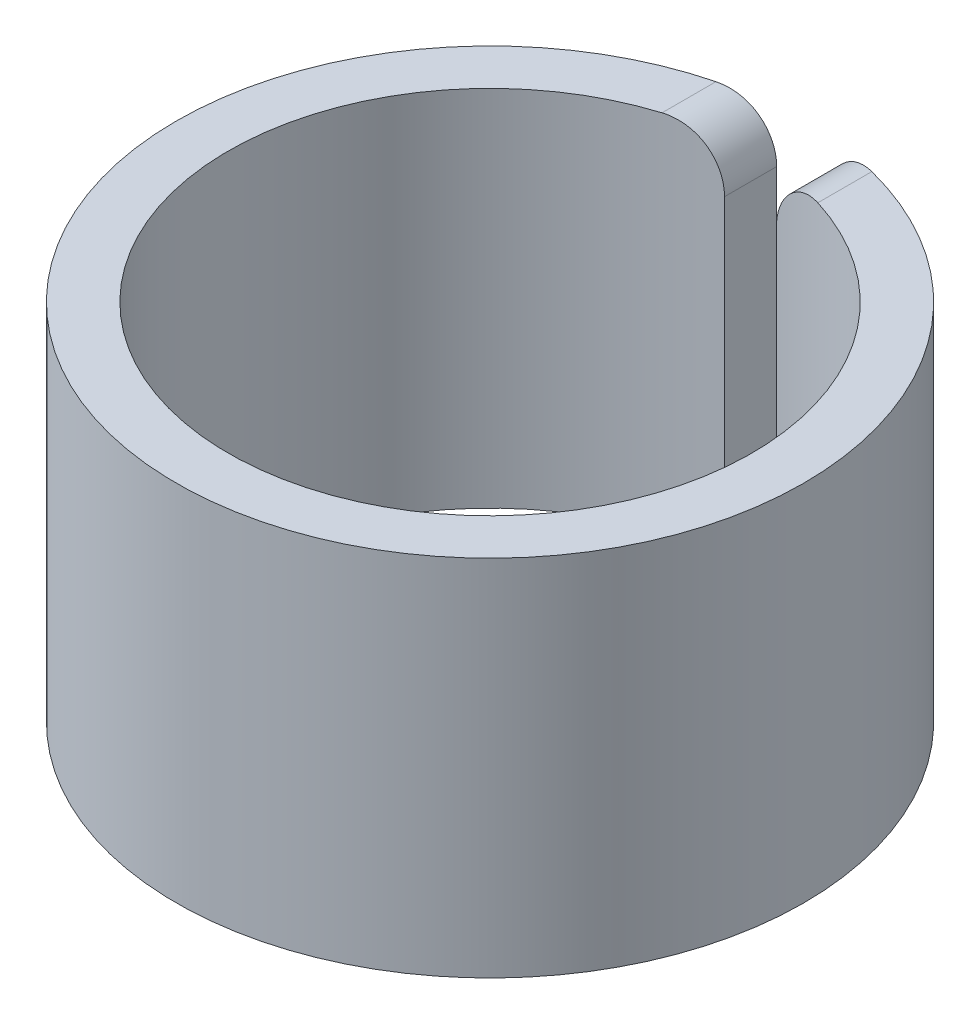
from build123d import *

# Parameters (mm, degrees)
SKETCH3_R               = 6.04
SKETCH3_R_2             = 5.04
EXTRUDE_THIN1_DEPTH     = 3.5
SKETCH4_W               = 1
SKETCH4_H               = 1000
CUT_EXTRUDE1_DEPTH      = 4.5
CUT_EXTRUDE1_DEPTH_BACK = 4.5
FILLET1_R               = 1


with BuildPart() as part:
    # Sketch3 → Extrude-Thin1 (new body, symmetric)
    with BuildSketch(Plane(origin=(0, 0, 0), x_dir=(1, 0, 0), z_dir=(0, 1, 0))):
        Circle(SKETCH3_R)
        Circle(SKETCH3_R_2, mode=Mode.SUBTRACT)
    extrude(amount=EXTRUDE_THIN1_DEPTH, both=True)

    # Sketch4 → Cut-Extrude1 (cut, two sides)
    with BuildSketch(Plane(origin=(0, 0, 0), x_dir=(1, 0, 0), z_dir=(0, 1, 0))) as cut_extrude1_sk:
        with Locations((0, 500)):
            Rectangle(SKETCH4_W, SKETCH4_H)
    extrude(amount=CUT_EXTRUDE1_DEPTH, mode=Mode.SUBTRACT)
    extrude(cut_extrude1_sk.sketch, amount=-CUT_EXTRUDE1_DEPTH_BACK, mode=Mode.SUBTRACT)

    # Fillet1
    fillet1_edges = [part.edges().sort_by_distance(p)[0] for p in [
        (0.5, -3.5, -5.517203073),
        (-0.5, -3.5, -5.517203073),
        (0.5, 3.5, -5.517203073),
        (-0.5, 3.5, -5.517203073),
    ]]
    fillet(fillet1_edges, radius=FILLET1_R)


solid = part.part
